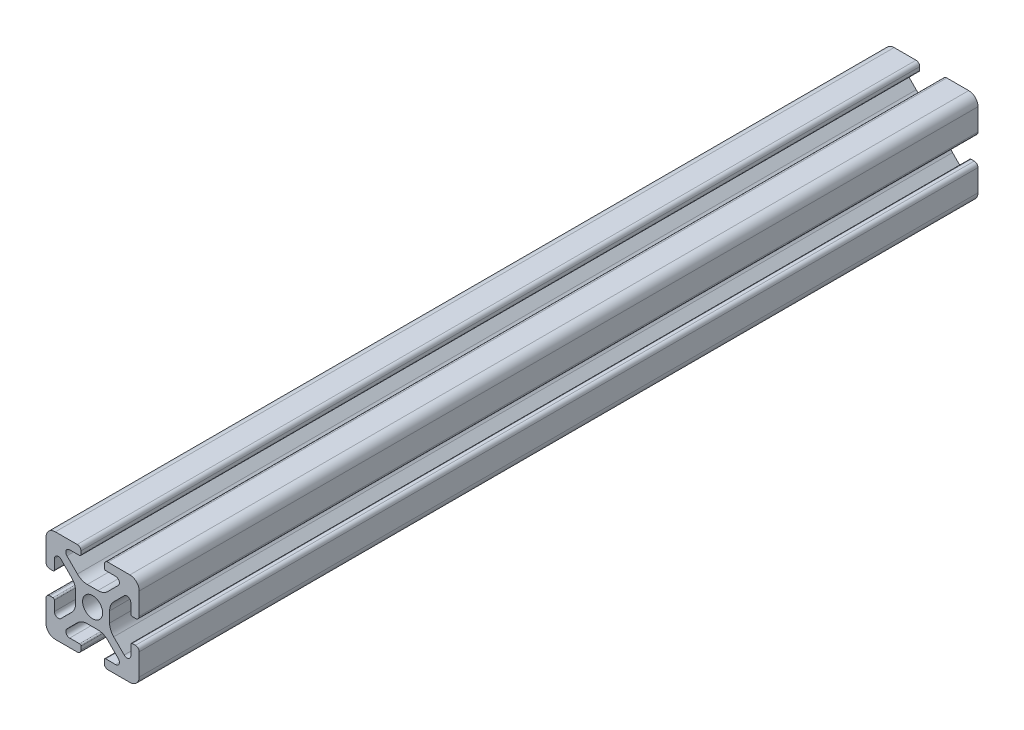
from build123d import *

# Parameters (mm, degrees)
SKETCH4_W              = 20
SKETCH4_H              = 20
BODY_DEPTH             = 180
SKETCH16_OUTSIDE_W     = 58.442
SKETCH16_OUTSIDE_H     = 58.442
SKETCH16_OUTSIDE_R     = 2.15
CUT_PROFILE_DEPTH      = 26
CUT_PROFILE_DEPTH_BACK = 156


with BuildPart() as part:
    # Sketch4 → Body (new body)
    with BuildSketch(Plane.XY.offset(25)):
        Rectangle(SKETCH4_W, SKETCH4_H)
    extrude(amount=-BODY_DEPTH)

    # Sketch16 outside → Cut-Profile (cut, two sides)
    with BuildSketch(Plane.XY) as cut_profile_sk:
        Rectangle(SKETCH16_OUTSIDE_W, SKETCH16_OUTSIDE_H)
        with BuildLine():
            Line((4.917588389, -8.199999991), (2.799999989, -8.199999991))
            ThreePointArc((2.799999989, -8.199999991), (2.587867955, -8.287867957), (2.499999989, -8.499999991))
            Line((2.499999989, -8.499999991), (2.499999989, -9.199999991))
            ThreePointArc((2.499999989, -9.199999991), (2.734314564, -9.765685416), (3.299999989, -9.999999991))
            Line((3.299999989, -9.999999991), (7.999999989, -9.999999991))
            ThreePointArc((7.999999989, -9.999999991), (9.414213552, -9.414213554), (9.999999989, -7.999999991))
            Line((9.999999989, -7.999999991), (9.999999989, -3.299999991))
            ThreePointArc((9.999999989, -3.299999991), (9.765685414, -2.734314566), (9.199999989, -2.499999991))
            Line((9.199999989, -2.499999991), (8.499999989, -2.499999991))
            ThreePointArc((8.499999989, -2.499999991), (8.287867955, -2.587867957), (8.199999989, -2.799999991))
            Line((8.199999989, -2.799999991), (8.199999989, -4.917588391))
            ThreePointArc((8.199999989, -4.917588391), (7.686138511, -5.686636441), (6.778984485, -5.506192286))
            Line((6.778984485, -5.506192286), (4.528679645, -3.255887446))
            ThreePointArc((4.528679645, -3.255887446), (3.878361392, -2.282617401), (3.64999999, -1.134567106))
            Line((3.64999999, -1.134567106), (3.64999999, 1.134567104))
            ThreePointArc((3.64999999, 1.134567104), (3.878361393, 2.282617402), (4.528679647, 3.255887448))
            Line((4.528679647, 3.255887448), (6.778984487, 5.506192288))
            ThreePointArc((6.778984487, 5.506192288), (7.686138506, 5.686636442), (8.199999981, 4.917588398))
            Line((8.199999981, 4.917588398), (8.199999981, 2.799999998))
            ThreePointArc((8.199999981, 2.799999998), (8.287867946, 2.587867964), (8.499999981, 2.499999998))
            Line((8.499999981, 2.499999998), (9.199999981, 2.499999998))
            ThreePointArc((9.199999981, 2.499999998), (9.765685406, 2.734314573), (9.999999981, 3.299999998))
            Line((9.999999981, 3.299999998), (9.999999981, 7.999999998))
            ThreePointArc((9.999999981, 7.999999998), (9.414213543, 9.41421356), (7.999999981, 9.999999998))
            Line((7.999999981, 9.999999998), (3.299999981, 9.999999998))
            ThreePointArc((3.299999981, 9.999999998), (2.734314556, 9.765685423), (2.499999981, 9.199999998))
            Line((2.499999981, 9.199999998), (2.499999981, 8.499999998))
            ThreePointArc((2.499999981, 8.499999998), (2.587867946, 8.287867964), (2.799999981, 8.199999998))
            Line((2.799999981, 8.199999998), (4.917588381, 8.199999998))
            ThreePointArc((4.917588381, 8.199999998), (5.68663643, 7.68613852), (5.506192275, 6.778984494))
            Line((5.506192275, 6.778984494), (3.255887435, 4.528679654))
            ThreePointArc((3.255887435, 4.528679654), (2.28261739, 3.878361401), (1.134567095, 3.649999999))
            Line((1.134567095, 3.649999999), (-1.134567115, 3.649999999))
            ThreePointArc((-1.134567115, 3.649999999), (-2.282617412, 3.878361401), (-3.255887459, 4.528679655))
            Line((-3.255887459, 4.528679655), (-5.506192299, 6.778984495))
            ThreePointArc((-5.506192299, 6.778984495), (-5.686636452, 7.686138515), (-4.917588409, 8.199999989))
            Line((-4.917588409, 8.199999989), (-2.800000009, 8.199999989))
            ThreePointArc((-2.800000009, 8.199999989), (-2.587867974, 8.287867955), (-2.500000009, 8.499999989))
            Line((-2.500000009, 8.499999989), (-2.500000009, 9.199999989))
            ThreePointArc((-2.500000009, 9.199999989), (-2.734314584, 9.765685414), (-3.300000009, 9.999999989))
            Line((-3.300000009, 9.999999989), (-8.000000009, 9.999999989))
            ThreePointArc((-8.000000009, 9.999999989), (-9.414213571, 9.414213552), (-10.000000009, 7.999999989))
            Line((-10.000000009, 7.999999989), (-10.000000009, 3.299999989))
            ThreePointArc((-10.000000009, 3.299999989), (-9.765685434, 2.734314564), (-9.200000009, 2.499999989))
            Line((-9.200000009, 2.499999989), (-8.500000009, 2.499999989))
            ThreePointArc((-8.500000009, 2.499999989), (-8.287867974, 2.587867955), (-8.200000009, 2.799999989))
            Line((-8.200000009, 2.799999989), (-8.200000009, 4.917588389))
            ThreePointArc((-8.200000009, 4.917588389), (-7.686138531, 5.686636438), (-6.778984504, 5.506192284))
            Line((-6.778984504, 5.506192284), (-4.528679664, 3.255887444))
            ThreePointArc((-4.528679664, 3.255887444), (-3.878361412, 2.282617399), (-3.650000009, 1.134567104))
            Line((-3.650000009, 1.134567104), (-3.650000009, -1.134567106))
            ThreePointArc((-3.650000009, -1.134567106), (-3.878361412, -2.282617404), (-4.528679666, -3.25588745))
            Line((-4.528679666, -3.25588745), (-6.778984506, -5.50619229))
            ThreePointArc((-6.778984506, -5.50619229), (-7.686138526, -5.686636444), (-8.2, -4.9175884))
            Line((-8.2, -4.9175884), (-8.2, -2.8))
            ThreePointArc((-8.2, -2.8), (-8.287867966, -2.587867966), (-8.5, -2.5))
            Line((-8.5, -2.5), (-9.2, -2.5))
            ThreePointArc((-9.2, -2.5), (-9.765685425, -2.734314575), (-10, -3.3))
            Line((-10, -3.3), (-10, -8))
            ThreePointArc((-10, -8), (-9.414213562, -9.414213562), (-8, -10))
            Line((-8, -10), (-3.3, -10))
            ThreePointArc((-3.3, -10), (-2.734314575, -9.765685425), (-2.5, -9.2))
            Line((-2.5, -9.2), (-2.5, -8.5))
            ThreePointArc((-2.5, -8.5), (-2.587867966, -8.287867966), (-2.8, -8.2))
            Line((-2.8, -8.2), (-4.9175884, -8.2))
            ThreePointArc((-4.9175884, -8.2), (-5.686636449, -7.686138522), (-5.506192294, -6.778984496))
            Line((-5.506192294, -6.778984496), (-3.255887454, -4.528679656))
            ThreePointArc((-3.255887454, -4.528679656), (-2.282617409, -3.878361403), (-1.134567114, -3.650000001))
            Line((-1.134567114, -3.650000001), (1.134567096, -3.650000001))
            ThreePointArc((1.134567096, -3.650000001), (2.282617393, -3.878361403), (3.255887439, -4.528679657))
            Line((3.255887439, -4.528679657), (5.506192279, -6.778984497))
            ThreePointArc((5.506192279, -6.778984497), (5.686636433, -7.686138517), (4.917588389, -8.199999991))
        make_face(mode=Mode.SUBTRACT)
        Circle(SKETCH16_OUTSIDE_R)
    extrude(amount=CUT_PROFILE_DEPTH, mode=Mode.SUBTRACT)
    extrude(cut_profile_sk.sketch, amount=-CUT_PROFILE_DEPTH_BACK, mode=Mode.SUBTRACT)


solid = part.part
